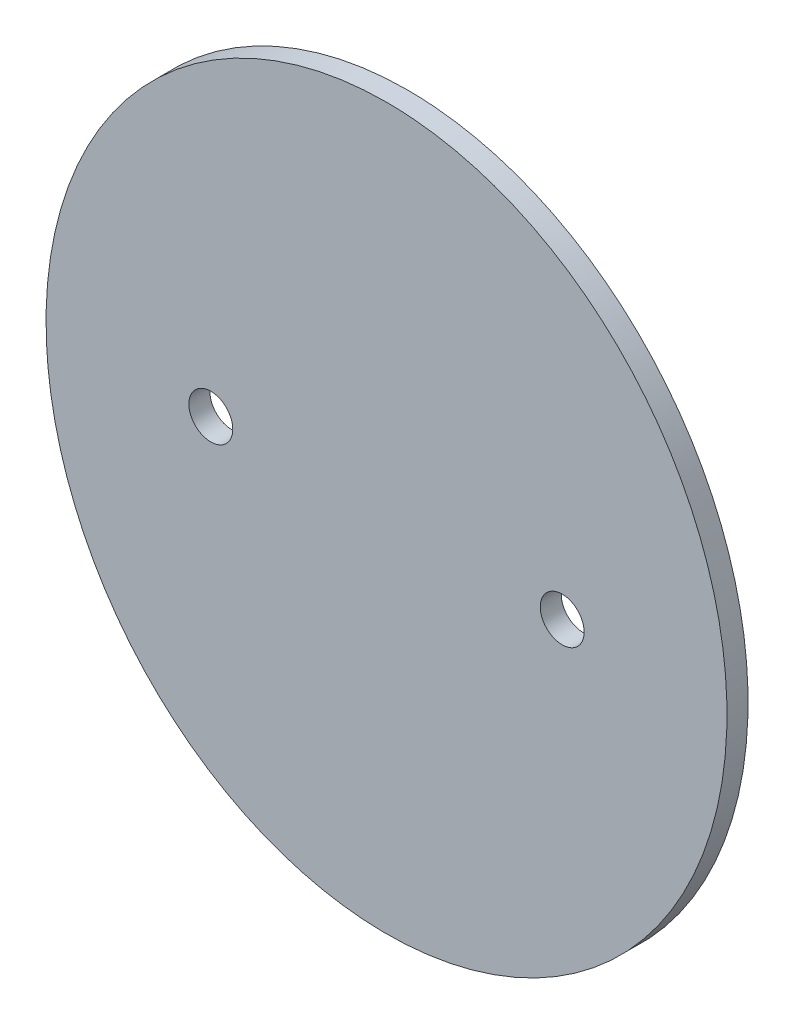
from build123d import *

# Parameters (mm, degrees)
SKETCH1_RX          = 102.5
SKETCH1_RY          = 96.9
SKETCH1_R           = 6.25
BOSS_EXTRUDE1_DEPTH = 6


with BuildPart() as part:
    # Sketch1 → Boss-Extrude1 (new body)
    with BuildSketch(Plane.XY):
        with Locations(Location((0, 0), (0, 0, 90))):
            Ellipse(SKETCH1_RX, SKETCH1_RY)
        with Locations((-50, 0)):
            Circle(SKETCH1_R, mode=Mode.SUBTRACT)
        with Locations((50, 0)):
            Circle(SKETCH1_R, mode=Mode.SUBTRACT)
    extrude(amount=BOSS_EXTRUDE1_DEPTH)


solid = part.part
